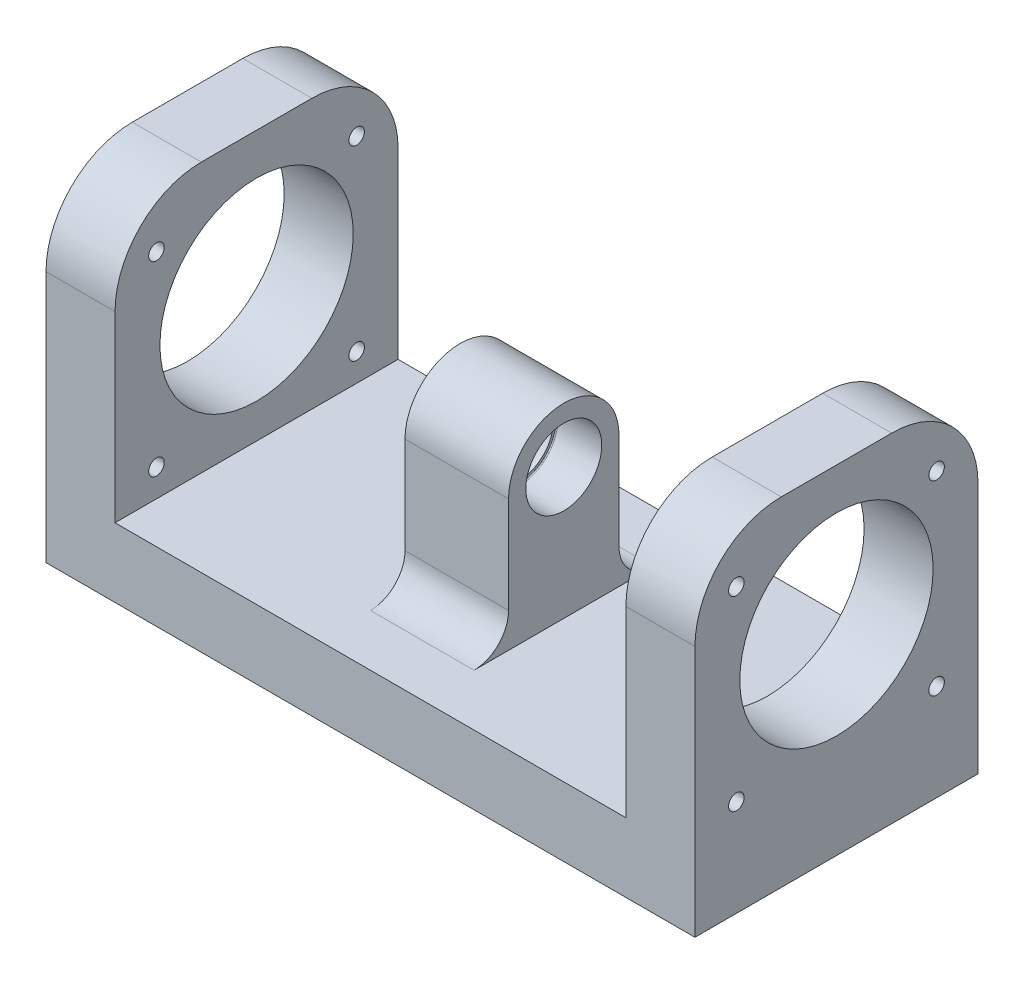
from build123d import *

# Parameters (mm, degrees)
BOSS_EXTRUDE1_DEPTH      = 82
SKETCH5_R                = 11
CUT_EXTRUDE1_DEPTH       = 13
CUT_EXTRUDE2_REACH       = 4
SKETCH6_R                = 10
FILLET1_R                = 0.3
CUT_EXTRUDE4_REACH       = 22
SKETCH8_R                = 28
CUT_EXTRUDE5_REACH       = 96
FILLET3_R                = 25
FILLET7_R                = 10
CUT_EXTRUDE7_DEPTH       = 10
M4_CLEARANCE_HOLE2_D     = 4.5
M4_CLEARANCE_HOLE2_DEPTH = 10
M4_CLEARANCE_HOLE2_TIP   = 1.351936393
M4_CLEARANCE_HOLE3_D     = 4.5
M4_CLEARANCE_HOLE3_DEPTH = 20


with BuildPart() as part:
    # Sketch1 → Boss-Extrude1 (new body)
    with BuildSketch(Plane.XY):
        Polygon((0, 0), (-74, 0), (-94, 0), (-94, 98), (-74, 98), (-74, 20), (-15, 20), (-15, 74), (0, 74), align=None)
    extrude(amount=-BOSS_EXTRUDE1_DEPTH)

    # Sketch5 → Cut-Extrude1 (cut)
    with BuildSketch(Plane.ZY.offset(15)):
        with Locations((-41, 58)):
            Circle(SKETCH5_R)
    extrude(amount=-CUT_EXTRUDE1_DEPTH, mode=Mode.SUBTRACT)

    # Sketch6 → Cut-Extrude2 (cut, up to next)
    with BuildSketch(Plane.ZY.offset(2), mode=Mode.PRIVATE) as cut_extrude2_sk1:
        with Locations((-41, 58)):
            Circle(SKETCH6_R)
    cut_extrude2_tool1 = extrude(cut_extrude2_sk1.sketch, amount=-CUT_EXTRUDE2_REACH, mode=Mode.PRIVATE) & part.part
    add(cut_extrude2_tool1.solids().sort_by_distance((-2, 58, -41))[0], mode=Mode.SUBTRACT)

    # Fillet1
    fillet1_edges = [part.edges().sort_by_distance(p)[0] for p in [
        (-2, 58, -52),
    ]]
    fillet(fillet1_edges, radius=FILLET1_R)

    # Sketch8 → Cut-Extrude4 (cut, up to next)
    with BuildSketch(Plane(origin=(-74, 0, 0), x_dir=(0, 0, -1), z_dir=(1, 0, 0)), mode=Mode.PRIVATE) as cut_extrude4_sk1:
        with Locations((41, 58)):
            Circle(SKETCH8_R)
    cut_extrude4_tool1 = extrude(cut_extrude4_sk1.sketch, amount=-CUT_EXTRUDE4_REACH, mode=Mode.PRIVATE) & part.part
    add(cut_extrude4_tool1.solids().sort_by_distance((-74, 58, -41))[0], mode=Mode.SUBTRACT)

    # Sketch10 → Cut-Extrude5 (cut, up to next)
    with BuildSketch(Plane(origin=(0, 0, 0), x_dir=(0, 0, -1), z_dir=(1, 0, 0)), mode=Mode.PRIVATE) as cut_extrude5_sk1:
        with BuildLine():
            Line((0, 74), (0, 20))
            Line((0, 20), (25, 20))
            Line((25, 20), (25, 58))
            ThreePointArc((25, 58), (29.686291501, 69.313708499), (41, 74))
            Line((41, 74), (0, 74))
        make_face()
    cut_extrude5_tool1 = extrude(cut_extrude5_sk1.sketch, amount=-CUT_EXTRUDE5_REACH, mode=Mode.PRIVATE) & part.part
    add(cut_extrude5_tool1.solids().sort_by_distance((0, 47.916044, -13.128546))[0], mode=Mode.SUBTRACT)
    # Sketch10 → Cut-Extrude5 (cut, up to next)
    with BuildSketch(Plane(origin=(0, 0, 0), x_dir=(0, 0, -1), z_dir=(1, 0, 0)), mode=Mode.PRIVATE) as cut_extrude5_sk2:
        with BuildLine():
            Line((82, 74), (41, 74))
            ThreePointArc((41, 74), (52.313708499, 69.313708499), (57, 58))
            Line((57, 58), (57, 20))
            Line((57, 20), (82, 20))
            Line((82, 20), (82, 74))
        make_face()
    cut_extrude5_tool2 = extrude(cut_extrude5_sk2.sketch, amount=-CUT_EXTRUDE5_REACH, mode=Mode.PRIVATE) & part.part
    add(cut_extrude5_tool2.solids().sort_by_distance((0, 47.916044, -68.871454))[0], mode=Mode.SUBTRACT)

    # Fillet3
    fillet3_edges = [part.edges().sort_by_distance(p)[0] for p in [
        (-84, 98, 0),
        (-84, 98, -82),
    ]]
    fillet(fillet3_edges, radius=FILLET3_R)

    # Fillet7
    fillet7_edges = [part.edges().sort_by_distance(p)[0] for p in [
        (-7.5, 20, -57),
        (-7.5, 20, -25),
    ]]
    fillet(fillet7_edges, radius=FILLET7_R)

    # Sketch16 → Cut-Extrude7 (cut)
    with BuildSketch(Plane.XZ):
        with BuildLine():
            Line((0, -9.457), (0, -14.457))
            ThreePointArc((0, -14.457), (-26.543, -41), (0, -67.543))
            Line((0, -67.543), (0, -72.543))
            ThreePointArc((0, -72.543), (-31.543, -41), (0, -9.457))
        make_face()
    extrude(amount=-CUT_EXTRUDE7_DEPTH, mode=Mode.SUBTRACT)

    # M4 Clearance Hole2
    with Locations(Plane(origin=(0, 0, 0), x_dir=(-1, 0, 0), z_dir=(0, -1, 0))):
        with Locations((40, 9.457), (40, 72.543)):
            Hole(M4_CLEARANCE_HOLE2_D / 2, depth=M4_CLEARANCE_HOLE2_DEPTH)
            with Locations((0, 0, -(M4_CLEARANCE_HOLE2_DEPTH + M4_CLEARANCE_HOLE2_TIP / 2))):  # 118° drill point
                Cone(0, M4_CLEARANCE_HOLE2_D / 2, M4_CLEARANCE_HOLE2_TIP, mode=Mode.SUBTRACT)

    # M4 Clearance Hole3
    with Locations(Plane.ZY.offset(94)):
        with Locations((-70, 28), (-12, 28), (-12, 82), (-70, 82)):
            Hole(M4_CLEARANCE_HOLE3_D / 2, depth=M4_CLEARANCE_HOLE3_DEPTH)

    # Mirror1: part across plane


with BuildPart() as part_1:
    add(part.part)
    add(part.part.mirror(Plane(origin=(0, 74, -82), x_dir=(0, 0, 1), z_dir=(1, 0, 0))))


solid = part_1.part
